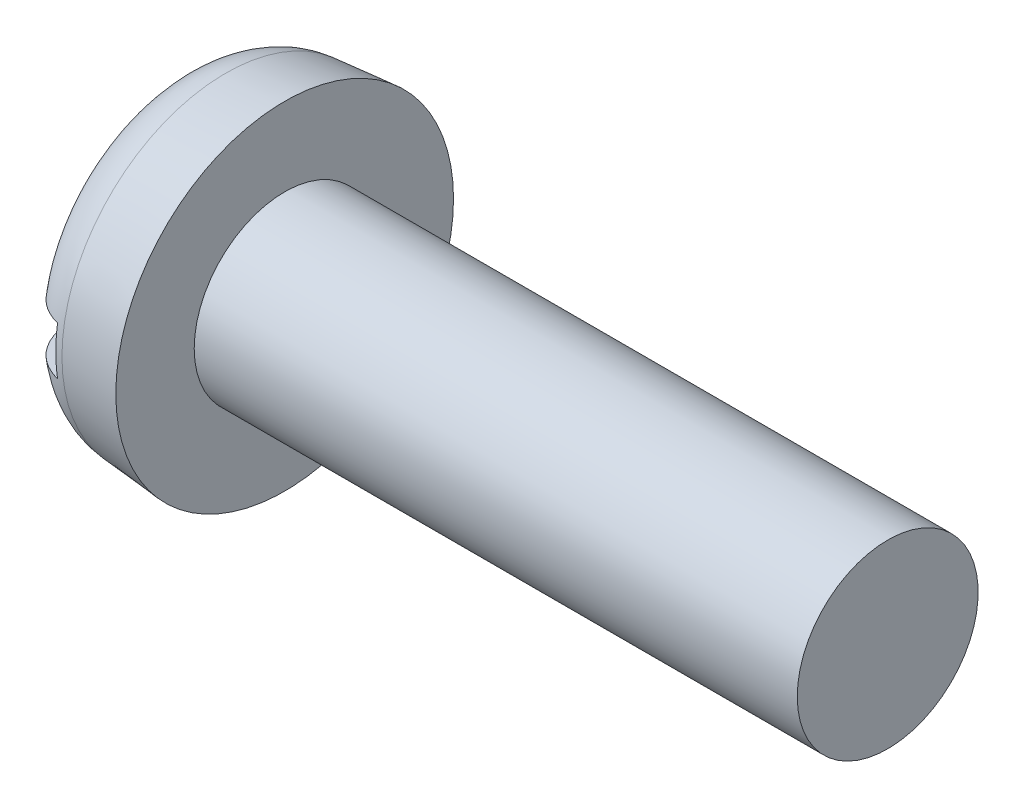
from build123d import *

# Parameters (mm, degrees)
FILLET2_R  = 0.9
SKETCH2_W  = 5.6
SKETCH2_H  = 0.8
SLOT_DEPTH = 0.7


with BuildPart() as part:
    # BodySke → Base-Revolve (revolve)
    with BuildSketch(Plane.XY, mode=Mode.PRIVATE) as base_revolve_sk:
        Polygon((1.8, 1.5), (1.8, 2.8), (0, 2.642520406), (0, 0), (11.8, 0), (11.8, 1.5), align=None)
    revolve(base_revolve_sk.sketch.rotate(Axis((-25.4, 0, 0), (1, 0, 0)), 90), axis=Axis((-25.4, 0, 0), (1, 0, 0)))  # turned: the seam where the file's is

    # Fillet2
    fillet2_edges = [part.edges().sort_by_distance(p)[0] for p in [
        (0, 0, -2.642520406),
    ]]
    fillet(fillet2_edges, radius=FILLET2_R)

    # Sketch2 → Slot (cut)
    with BuildSketch(Plane(origin=(0, 0, 0), x_dir=(0, 0, -1), z_dir=(1, 0, 0))):
        Rectangle(SKETCH2_W, SKETCH2_H)
    extrude(amount=SLOT_DEPTH, mode=Mode.SUBTRACT)


solid = part.part
